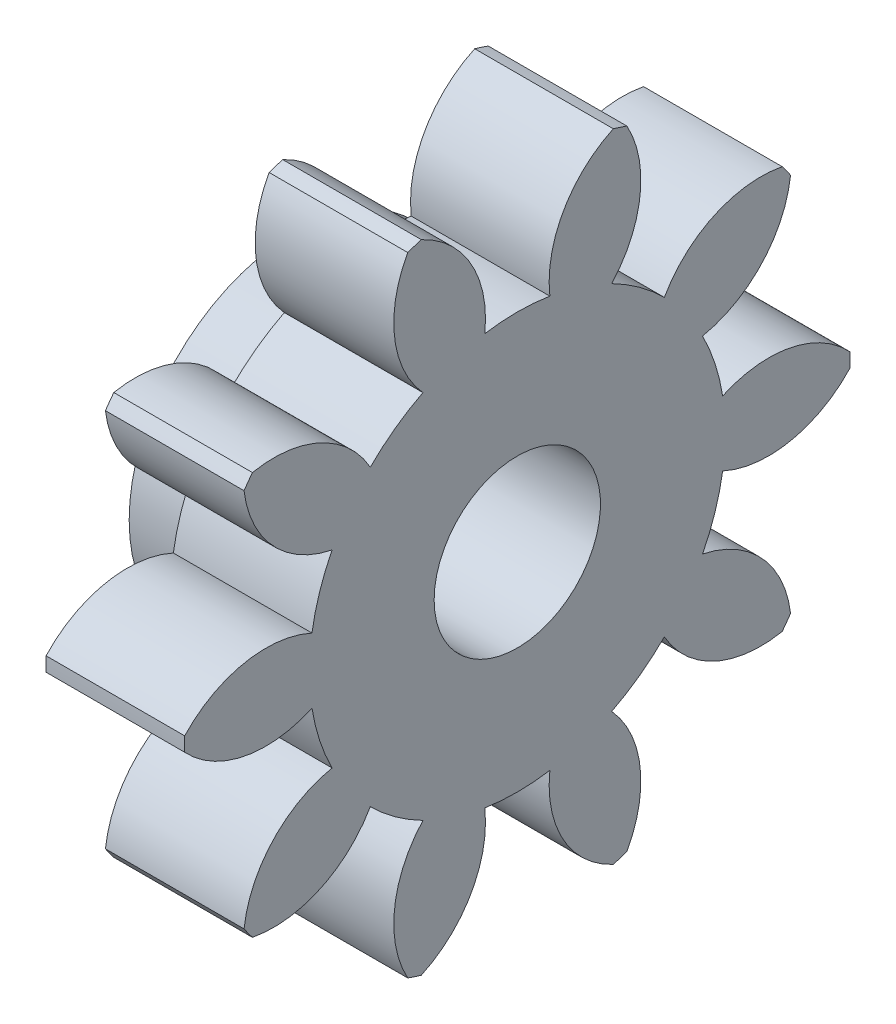
from build123d import *

# Parameters (mm, degrees)
BASPROSKE_W      = 5
BASPROSKE_H      = 12
TOOTHCUT_DEPTH   = 18.691806013
TEETHCUTS_COUNT  = 10
TEETHCUTS_ANGLE  = 324
HUBNEAONESKE_R   = 6
HUBNEARONE_DEPTH = 3.0000508
BORSKE_R         = 3
BORE_DEPTH       = 8.0000508


with BuildPart() as part:
    # BasProSke → Base-Revolve (revolve)
    with BuildSketch(Plane(origin=(0, 0, 0), x_dir=(1, 0, 0), z_dir=(0, 1, 0)), mode=Mode.PRIVATE) as base_revolve_sk:
        with Locations((2.5, 6)):
            Rectangle(BASPROSKE_W, BASPROSKE_H)
    revolve(base_revolve_sk.sketch.rotate(Axis((-10, 0, 0), (1, 0, 0)), 180), axis=Axis((-10, 0, 0), (1, 0, 0)))

    # TooCutSke → ToothCut (cut, through all)
    with BuildSketch(Plane(origin=(0, 0, 0), x_dir=(0, 0, -1), z_dir=(1, 0, 0))):
        with BuildLine():
            ThreePointArc((1.173662691, 7.406586048), (0, 7.499), (-1.173662691, 7.406586048))
            ThreePointArc((-1.173662691, 7.406586048), (-1.668191438, 9.834565786), (-3.497907776, 11.50542856))
            ThreePointArc((-3.497907776, 11.50542856), (0, 12.0254), (3.497907776, 11.50542856))
            ThreePointArc((3.497907776, 11.50542856), (1.668191438, 9.834565786), (1.173662691, 7.406586048))
        make_face()
    toothcut = extrude(amount=TOOTHCUT_DEPTH, mode=Mode.SUBTRACT)

    # TeethCuts: ToothCut ×10 about axis
    teethcuts_axis = Axis((-10, 0, 0), (1, 0, 0))
    for i in range(1, TEETHCUTS_COUNT):
        add(toothcut.rotate(teethcuts_axis, i * TEETHCUTS_ANGLE / (TEETHCUTS_COUNT - 1)), mode=Mode.SUBTRACT)

    # HubNeaOneSke → HubNearOne (add)
    with BuildSketch(Plane.ZY):
        with Locations(Location((0, 0, 0), (0, 0, 180))):
            Circle(HUBNEAONESKE_R)
    extrude(amount=HUBNEARONE_DEPTH)

    # BorSke → Bore (cut, symmetric)
    with BuildSketch(Plane(origin=(0, 0, 0), x_dir=(0, 0, -1), z_dir=(1, 0, 0))):
        with Locations(Location((0, 0, 0), (0, 0, 180))):
            Circle(BORSKE_R)
    extrude(amount=BORE_DEPTH, both=True, mode=Mode.SUBTRACT)


solid = part.part
